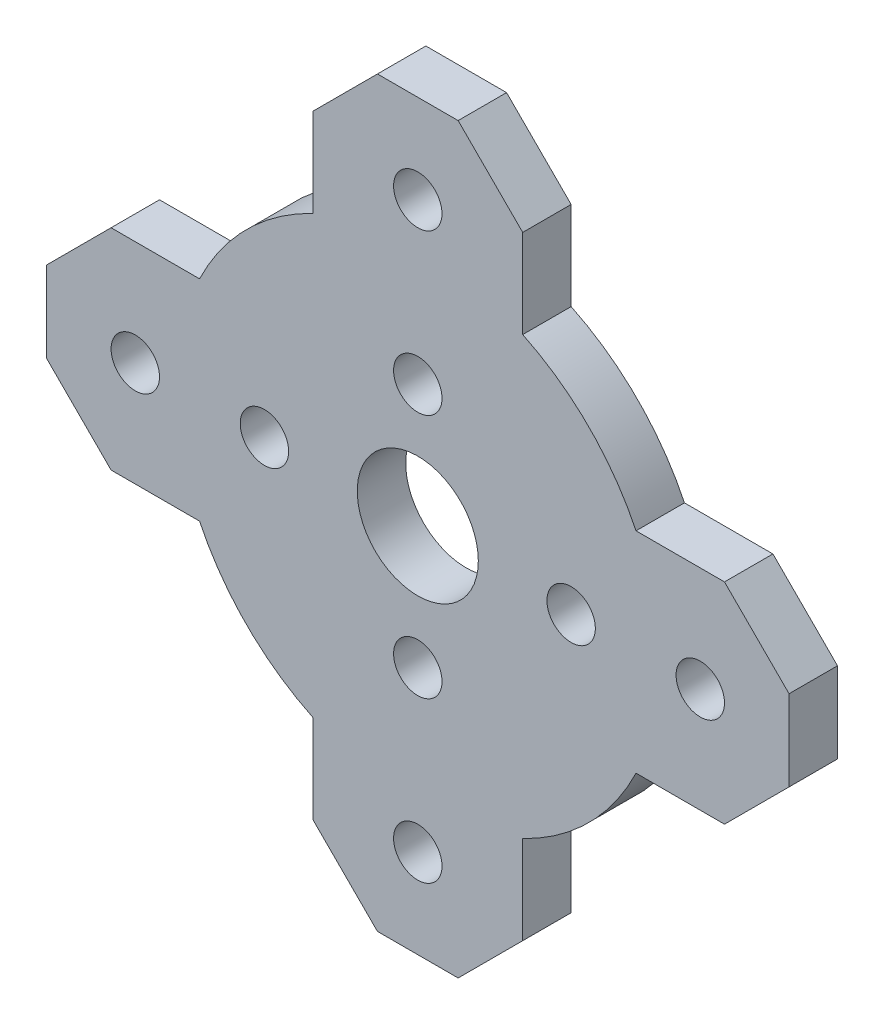
from build123d import *

# Parameters (mm, degrees)
SKETCH1_R           = 1.5
SKETCH1_R_2         = 3.75
BOSS_EXTRUDE1_DEPTH = 3
CHAMFER1_SIZE       = 4


with BuildPart() as part:
    # Sketch1 → Boss-Extrude1 (new body)
    with BuildSketch(Plane.XY):
        with BuildLine():
            Line((-6.5, 23), (6.5, 23))
            Line((6.5, 23), (6.5, 13.518505835))
            ThreePointArc((6.5, 13.518505835), (10.606601718, 10.606601718), (13.518505835, 6.5))
            Line((13.518505835, 6.5), (23, 6.5))
            Line((23, 6.5), (23, -6.5))
            Line((23, -6.5), (13.518505835, -6.5))
            ThreePointArc((13.518505835, -6.5), (10.606601718, -10.606601718), (6.5, -13.518505835))
            Line((6.5, -13.518505835), (6.5, -23))
            Line((6.5, -23), (-6.5, -23))
            Line((-6.5, -23), (-6.5, -13.518505835))
            ThreePointArc((-6.5, -13.518505835), (-10.606601718, -10.606601718), (-13.518505835, -6.5))
            Line((-13.518505835, -6.5), (-23, -6.5))
            Line((-23, -6.5), (-23, 6.5))
            Line((-23, 6.5), (-13.518505835, 6.5))
            ThreePointArc((-13.518505835, 6.5), (-10.606601718, 10.606601718), (-6.5, 13.518505835))
            Line((-6.5, 13.518505835), (-6.5, 23))
        make_face()
        with Locations((0, 7.6)):
            Circle(SKETCH1_R, mode=Mode.SUBTRACT)
        with Locations((9.5, 0)):
            Circle(SKETCH1_R, mode=Mode.SUBTRACT)
        with Locations((-9.5, 0)):
            Circle(SKETCH1_R, mode=Mode.SUBTRACT)
        with Locations((0, -7.6)):
            Circle(SKETCH1_R, mode=Mode.SUBTRACT)
        with Locations((0, 17.5)):
            Circle(SKETCH1_R, mode=Mode.SUBTRACT)
        with Locations((17.5, 0)):
            Circle(SKETCH1_R, mode=Mode.SUBTRACT)
        with Locations((0, -17.5)):
            Circle(SKETCH1_R, mode=Mode.SUBTRACT)
        with Locations((-17.5, 0)):
            Circle(SKETCH1_R, mode=Mode.SUBTRACT)
        Circle(SKETCH1_R_2, mode=Mode.SUBTRACT)
    extrude(amount=BOSS_EXTRUDE1_DEPTH)

    # Chamfer1
    chamfer1_edges = [part.edges().sort_by_distance(p)[0] for p in [
        (23, 6.5, 1.5),
        (23, -6.5, 1.5),
        (6.5, -23, 1.5),
        (-6.5, -23, 1.5),
        (-23, -6.5, 1.5),
        (-23, 6.5, 1.5),
        (-6.5, 23, 1.5),
        (6.5, 23, 1.5),
    ]]
    chamfer(chamfer1_edges, length=CHAMFER1_SIZE)


solid = part.part
